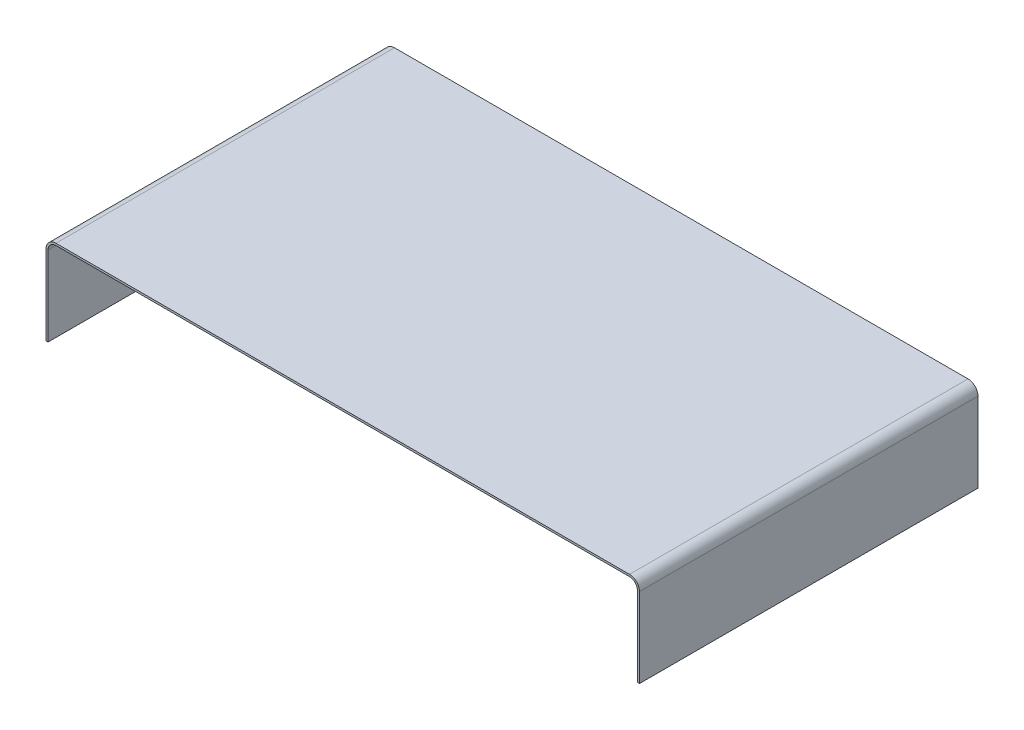
from build123d import *

# Parameters (mm, degrees)
RESSALTO_EXTRUS_O1_DEPTH = 170


with BuildPart() as part:
    # Esboço1 → Ressalto-extrusão1 (new body)
    with BuildSketch(Plane.XY):
        with BuildLine():
            Line((0, 0), (0, 40))
            ThreePointArc((0, 40), (1.464466094, 43.535533906), (5, 45))
            Line((5, 45), (293, 45))
            ThreePointArc((293, 45), (296.535533906, 43.535533906), (298, 40))
            Line((298, 40), (298, 0))
            Line((298, 0), (297, 0))
            Line((297, 0), (297, 40))
            ThreePointArc((297, 40), (295.828427125, 42.828427125), (293, 44))
            Line((293, 44), (5, 44))
            ThreePointArc((5, 44), (2.171572875, 42.828427125), (1, 40))
            Line((1, 40), (1, 0))
            Line((1, 0), (0, 0))
        make_face()
    extrude(amount=RESSALTO_EXTRUS_O1_DEPTH)


solid = part.part
